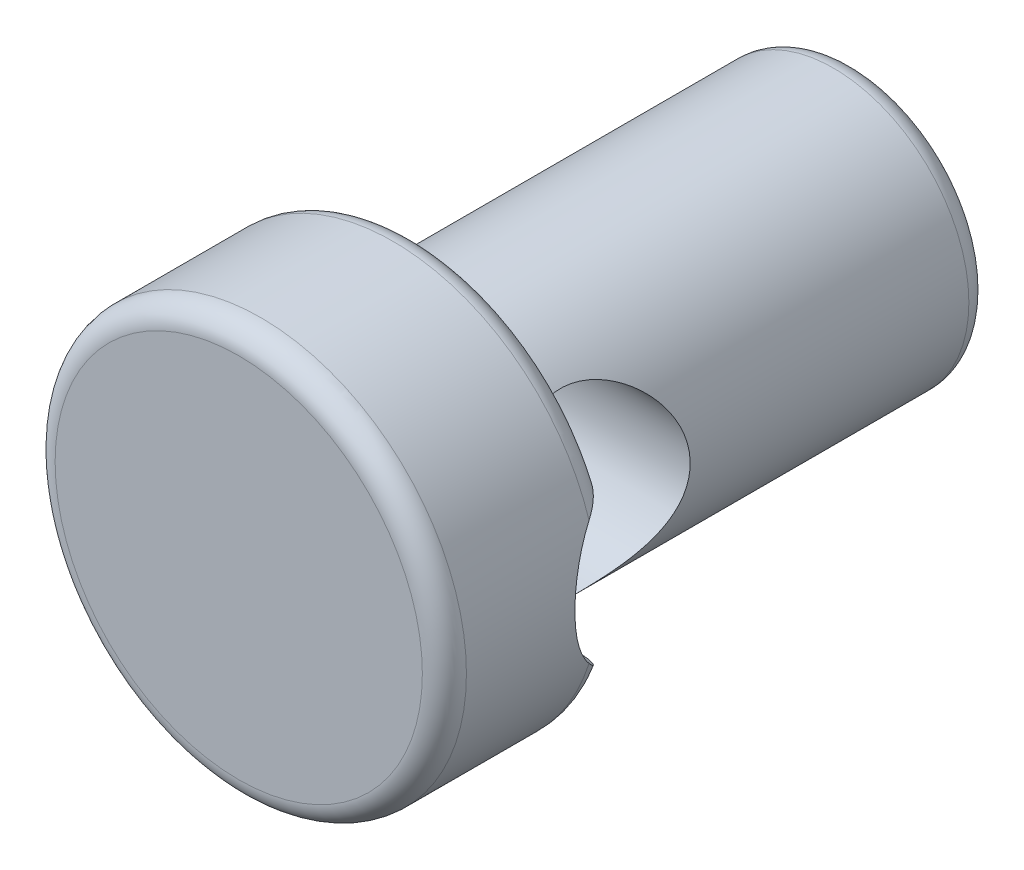
from build123d import *

# Parameters (mm, degrees)
SKETCH1_R               = 24.568302704
EXTRUDE1_DEPTH          = 80
SKETCH2_R               = 37.339605778
EXTRUDE2_DEPTH          = 32
FILLET1_R               = 4
CUT_EXTRUDE1_DEPTH      = 32
CUT_EXTRUDE1_DEPTH_BACK = 77
SKETCH3_R               = 16.855421097


with BuildPart() as part:
    # Sketch1 → Extrude1 (new body)
    with BuildSketch(Plane.XY):
        Circle(SKETCH1_R)
    extrude(amount=EXTRUDE1_DEPTH)

    # Sketch2 → Extrude2 (add)
    with BuildSketch(Plane.XY.offset(80)):
        Circle(SKETCH2_R)
    extrude(amount=EXTRUDE2_DEPTH)

    # Fillet1
    fillet1_edges = [part.edges().sort_by_distance(p)[0] for p in [
        (-24.568302704, 0, 0),
        (-24.568302704, 0, 80),
        (-37.339605778, 0, 80),
        (-37.339605778, 0, 112),
    ]]
    fillet(fillet1_edges, radius=FILLET1_R)

    # Sketch3 → Cut-Extrude1 (cut, two sides: drawn at the far end of the back side and taken through both)
    with BuildSketch(Plane(origin=(25, 0, 0), x_dir=(0, 0, -1), z_dir=(1, 0, 0)).offset(-CUT_EXTRUDE1_DEPTH_BACK)):
        with Locations(Location((-71.449956272, 0, 0), (0, 0, 221.877807058))):
            Circle(SKETCH3_R)
    extrude(amount=CUT_EXTRUDE1_DEPTH + CUT_EXTRUDE1_DEPTH_BACK, mode=Mode.SUBTRACT)


solid = part.part
